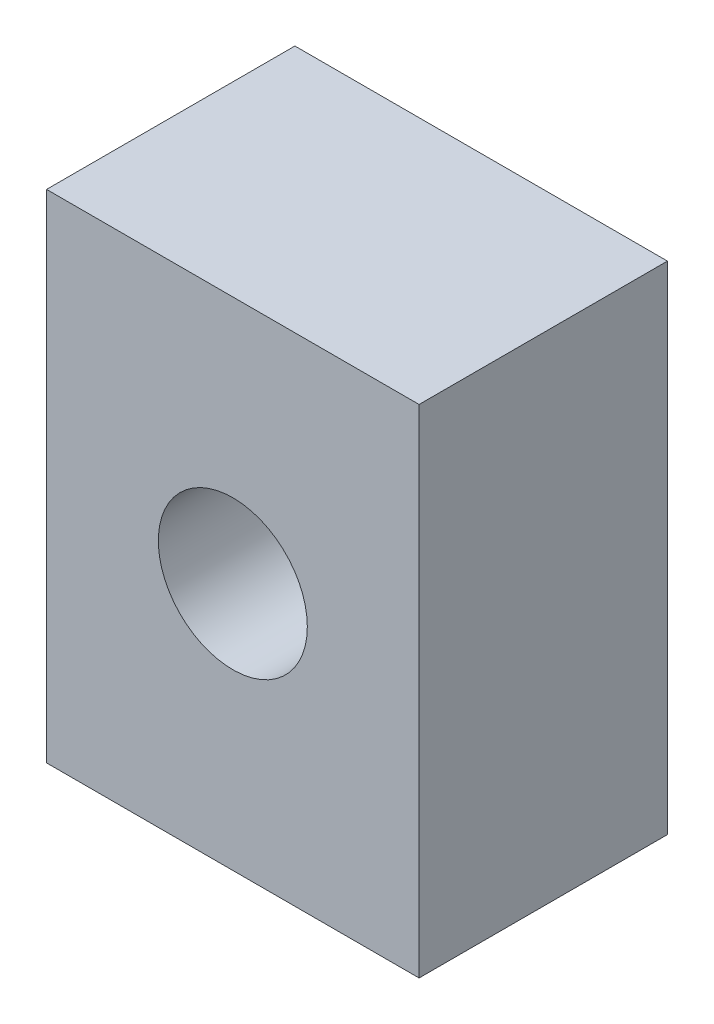
from build123d import *

# Parameters (mm, degrees)
SKETCH1_W           = 30
SKETCH1_H           = 40
BOSS_EXTRUDE1_DEPTH = 20
SKETCH2_R           = 6
CUT_EXTRUDE1_DEPTH  = 12


with BuildPart() as part:
    # Sketch1 → Boss-Extrude1 (new body)
    with BuildSketch(Plane.XY):
        with Locations((15, 20)):
            Rectangle(SKETCH1_W, SKETCH1_H)
    extrude(amount=BOSS_EXTRUDE1_DEPTH)

    # Sketch2 → Cut-Extrude1 (cut)
    with BuildSketch(Plane.XY.offset(20)):
        with Locations((15, 20)):
            Circle(SKETCH2_R)
    extrude(amount=-CUT_EXTRUDE1_DEPTH, mode=Mode.SUBTRACT)


solid = part.part
